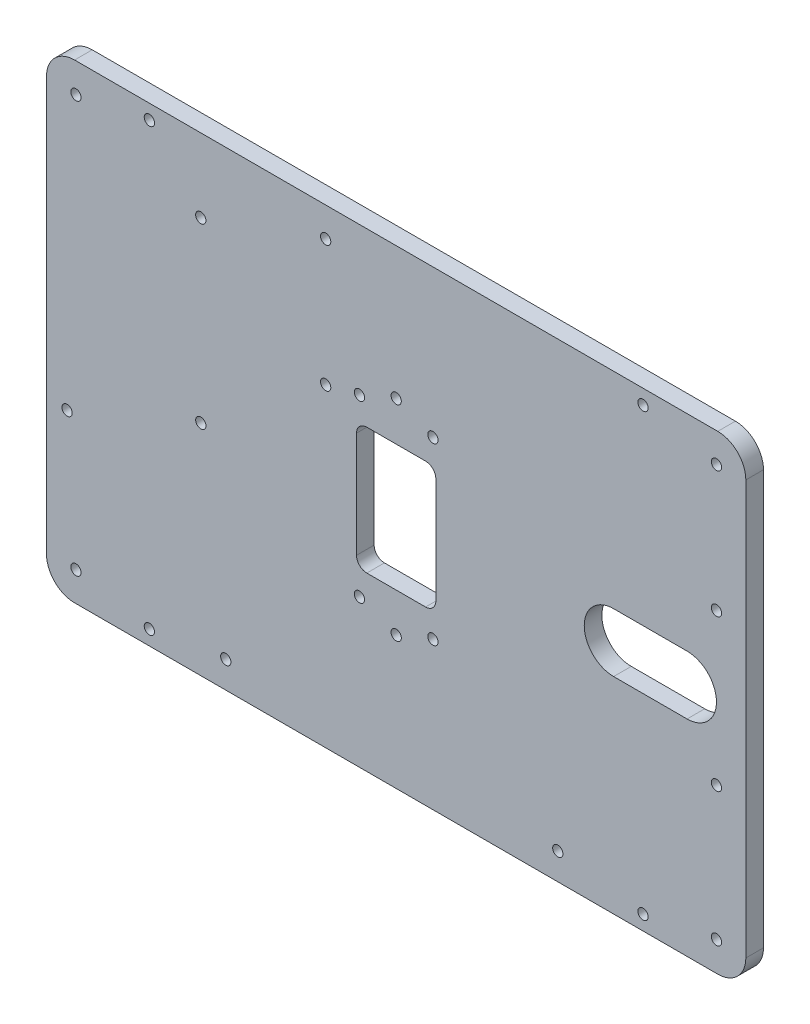
from build123d import *

# Parameters (mm, degrees)
ESQUISSE1_R        = 1.75
ESQUISSE1_W        = 27
ESQUISSE1_H        = 43
BOSS_EXTRU_1_DEPTH = 6
CONG_1_R           = 3.5


with BuildPart() as part:
    # Esquisse1 → Boss.-Extru.1 (new body)
    with BuildSketch(Plane.XY):
        with BuildLine():
            Line((109.450836441, 80), (-109.450836441, 80))
            ThreePointArc((-109.450836441, 80), (-116.203114748, 77.203114748), (-119, 70.450836441))
            Line((-119, 70.450836441), (-119, -70.450836441))
            ThreePointArc((-119, -70.450836441), (-116.203114748, -77.203114748), (-109.450836441, -80))
            Line((-109.450836441, -80), (109.450836441, -80))
            ThreePointArc((109.450836441, -80), (116.203114748, -77.203114748), (119, -70.450836441))
            Line((119, -70.450836441), (119, 70.450836441))
            ThreePointArc((119, 70.450836441), (116.203114748, 77.203114748), (109.450836441, 80))
        make_face()
        with Locations((109, -70)):
            Circle(ESQUISSE1_R, mode=Mode.SUBTRACT)
        with Locations((109, 70)):
            Circle(ESQUISSE1_R, mode=Mode.SUBTRACT)
        with Locations((-24, 27)):
            Circle(ESQUISSE1_R, mode=Mode.SUBTRACT)
        with Locations((-24, 70)):
            Circle(ESQUISSE1_R, mode=Mode.SUBTRACT)
        with Locations((109, 27)):
            Circle(ESQUISSE1_R, mode=Mode.SUBTRACT)
        with Locations((109, -24.5)):
            Circle(ESQUISSE1_R, mode=Mode.SUBTRACT)
        with Locations((-112, -24.5)):
            Circle(ESQUISSE1_R, mode=Mode.SUBTRACT)
        with Locations((84, 75)):
            Circle(ESQUISSE1_R, mode=Mode.SUBTRACT)
        with Locations((84, -75)):
            Circle(ESQUISSE1_R, mode=Mode.SUBTRACT)
        with Locations((-109, -70)):
            Circle(ESQUISSE1_R, mode=Mode.SUBTRACT)
        with Locations((-109, 70)):
            Circle(ESQUISSE1_R, mode=Mode.SUBTRACT)
        with Locations((-84, -75)):
            Circle(ESQUISSE1_R, mode=Mode.SUBTRACT)
        with Locations((-84, 75)):
            Circle(ESQUISSE1_R, mode=Mode.SUBTRACT)
        with Locations((0, 35)):
            Circle(ESQUISSE1_R, mode=Mode.SUBTRACT)
        with Locations((0, -34.75)):
            Circle(ESQUISSE1_R, mode=Mode.SUBTRACT)
        with Locations((-12.5, 29.75)):
            Circle(ESQUISSE1_R, mode=Mode.SUBTRACT)
        with Locations((12.5, 29.75)):
            Circle(ESQUISSE1_R, mode=Mode.SUBTRACT)
        with Locations((12.5, -29.75)):
            Circle(ESQUISSE1_R, mode=Mode.SUBTRACT)
        with Locations((-12.5, -29.75)):
            Circle(ESQUISSE1_R, mode=Mode.SUBTRACT)
        with Locations((-66.5, 55)):
            Circle(ESQUISSE1_R, mode=Mode.SUBTRACT)
        with Locations((-66.5, -5.5)):
            Circle(ESQUISSE1_R, mode=Mode.SUBTRACT)
        with Locations((-58, -70.9)):
            Circle(ESQUISSE1_R, mode=Mode.SUBTRACT)
        with Locations((55, -70.9)):
            Circle(ESQUISSE1_R, mode=Mode.SUBTRACT)
        Rectangle(ESQUISSE1_W, ESQUISSE1_H, mode=Mode.SUBTRACT)
        with BuildLine():
            Line((99, -10), (74, -10))
            ThreePointArc((74, -10), (64, 0), (74, 10))
            Line((74, 10), (99, 10))
            ThreePointArc((99, 10), (109, 0), (99, -10))
        make_face(mode=Mode.SUBTRACT)
    extrude(amount=BOSS_EXTRU_1_DEPTH)

    # Congé1
    cong_1_edges = [part.edges().sort_by_distance(p)[0] for p in [
        (13.5, 21.5, 3),
        (-13.5, 21.5, 3),
        (-13.5, -21.5, 3),
        (13.5, -21.5, 3),
    ]]
    fillet(cong_1_edges, radius=CONG_1_R)


solid = part.part
